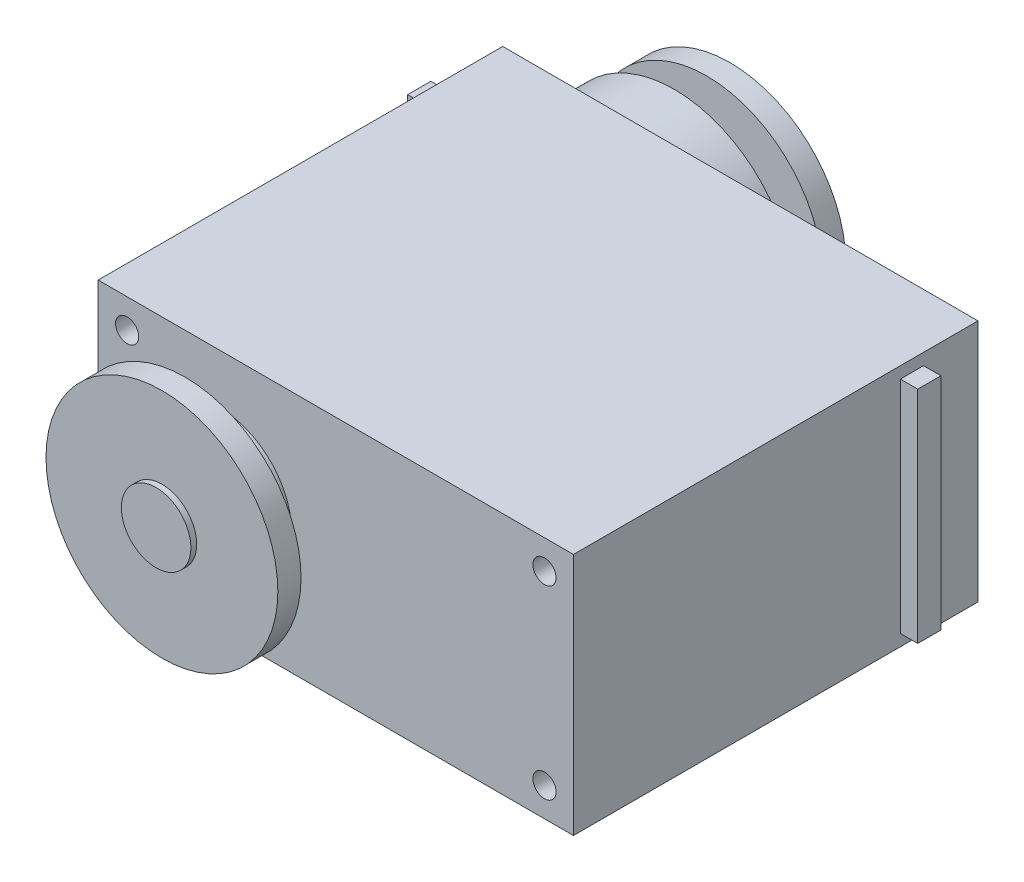
from build123d import *

# Parameters (mm, degrees)
SKETCH_1_W          = 41
SKETCH_1_H          = 21
EXTRUDE_1_DEPTH     = 34.9
SKETCH_2_R          = 5.9
SKETCH_2_R_2        = 10.4
EXTRUDE_2_DEPTH     = 4.3
SKETCH_3_R          = 5.75
EXTRUDE_3_DEPTH     = 1.2
SKETCH_4_R          = 3
EXTRUDE_4_DEPTH     = 3.4
SKETCH_5_W          = 2
SKETCH_5_H          = 19
EXTRUDE_5_DEPTH     = 1.5
SKETCH_6_R          = 6.2
EXTRUDE_6_DEPTH     = 2
SKETCH_7_R          = 3
EXTRUDE_7_DEPTH     = 3.5
SKETCH_8_R          = 1
CUT_EXTRUDE_1_DEPTH = 10
SKETCH_9_R          = 5
EXTRUDE_8_DEPTH     = 1
SKETCH_10_R         = 10
EXTRUDE_9_DEPTH     = 2
SKETCH_11_R         = 5
EXTRUDE_10_DEPTH    = 1.6
SKETCH_12_R         = 10
EXTRUDE_11_DEPTH    = 2


with BuildPart() as part:
    # 草圖1 → 填料-伸長1 (new body)
    with BuildSketch(Plane.XY):
        Rectangle(SKETCH_1_W, SKETCH_1_H)
    extrude(amount=EXTRUDE_1_DEPTH)

    # 草圖2 → 填料-伸長2 (add)
    with BuildSketch(Plane(origin=(0, 0, 0), x_dir=(-1, 0, 0), z_dir=(0, 0, -1))):
        with Locations((-1.2, 0)):
            Circle(SKETCH_2_R)
        with Locations((10, 0)):
            Circle(SKETCH_2_R_2)
    extrude(amount=EXTRUDE_2_DEPTH)

    # 草圖3 → 填料-伸長3 (add)
    with BuildSketch(Plane(origin=(0, 0, -4.3), x_dir=(-1, 0, 0), z_dir=(0, 0, -1))):
        with Locations((10, 0)):
            Circle(SKETCH_3_R)
    extrude(amount=EXTRUDE_3_DEPTH)

    # 草圖4 → 填料-伸長4 (add)
    with BuildSketch(Plane(origin=(0, 0, -5.5), x_dir=(-1, 0, 0), z_dir=(0, 0, -1))):
        with Locations((10, 0)):
            Circle(SKETCH_4_R)
    extrude(amount=EXTRUDE_4_DEPTH)

    # 草圖5 → 填料-伸長5 (add)
    with BuildSketch(Plane.ZY.offset(20.5)):
        with Locations((5.7, 0)):
            Rectangle(SKETCH_5_W, SKETCH_5_H)
    extrude_5 = extrude(amount=EXTRUDE_5_DEPTH)

    # 鏡射1: 填料-伸長5 across plane
    add(extrude_5.mirror(Plane(origin=(0, 0, 0), x_dir=(0, 0, 1), z_dir=(1, 0, 0))))

    # 草圖6 → 填料-伸長6 (add)
    with BuildSketch(Plane.XY.offset(34.9)):
        with Locations((-10, 0)):
            Circle(SKETCH_6_R)
    extrude(amount=EXTRUDE_6_DEPTH)

    # 草圖7 → 填料-伸長7 (add)
    with BuildSketch(Plane.XY.offset(36.9)):
        with Locations((-10, 0)):
            Circle(SKETCH_7_R)
    extrude(amount=EXTRUDE_7_DEPTH)

    # 草圖8 → 除料-伸長1 (cut)
    with BuildSketch(Plane.XY.offset(34.9)):
        with Locations((-18, 8)):
            Circle(SKETCH_8_R)
        with Locations((18, 8)):
            Circle(SKETCH_8_R)
        with Locations((18, -8)):
            Circle(SKETCH_8_R)
        with Locations((-18, -8)):
            Circle(SKETCH_8_R)
    extrude(amount=-CUT_EXTRUDE_1_DEPTH, mode=Mode.SUBTRACT)

    # 草圖9 → 填料-伸長8 (add)
    with BuildSketch(Plane.XY.offset(36.9)):
        with Locations((-10, 0)):
            Circle(SKETCH_9_R)
    extrude(amount=EXTRUDE_8_DEPTH)

    # 草圖10 → 填料-伸長9 (add)
    with BuildSketch(Plane.XY.offset(37.9)):
        with Locations((-10, 0)):
            Circle(SKETCH_10_R)
    extrude(amount=EXTRUDE_9_DEPTH)

    # 草圖11 → 填料-伸長10 (add)
    with BuildSketch(Plane(origin=(0, 0, -5.5), x_dir=(-1, 0, 0), z_dir=(0, 0, -1))):
        with Locations((10, 0)):
            Circle(SKETCH_11_R)
    extrude(amount=EXTRUDE_10_DEPTH)

    # 草圖12 → 填料-伸長11 (add)
    with BuildSketch(Plane(origin=(0, 0, -7.1), x_dir=(-1, 0, 0), z_dir=(0, 0, -1))):
        with Locations((10, 0)):
            Circle(SKETCH_12_R)
    extrude(amount=EXTRUDE_11_DEPTH)


solid = part.part
